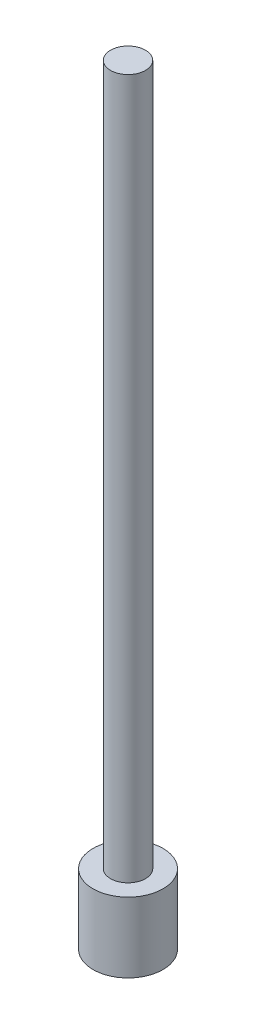
from build123d import *

# Parameters (mm, degrees)
SKETCH1_R           = 0.25
BOSS_EXTRUDE1_DEPTH = 10
SKETCH2_R           = 0.5
BOSS_EXTRUDE2_DEPTH = 1
SCALE1_SCALE        = 100


with BuildPart() as part:
    # Sketch1 → Boss-Extrude1 (new body)
    with BuildSketch(Plane(origin=(0, 0, 0), x_dir=(1, 0, 0), z_dir=(0, 1, 0))):
        Circle(SKETCH1_R)
    extrude(amount=-BOSS_EXTRUDE1_DEPTH)

    # Sketch2 → Boss-Extrude2 (add)
    with BuildSketch(Plane.XZ.offset(10)):
        Circle(SKETCH2_R)
    extrude(amount=BOSS_EXTRUDE2_DEPTH)


with BuildPart() as part_1:
    # Scale1: scaled about (0, 0, 0)
    add(part.part.scale(SCALE1_SCALE))


solid = part_1.part
